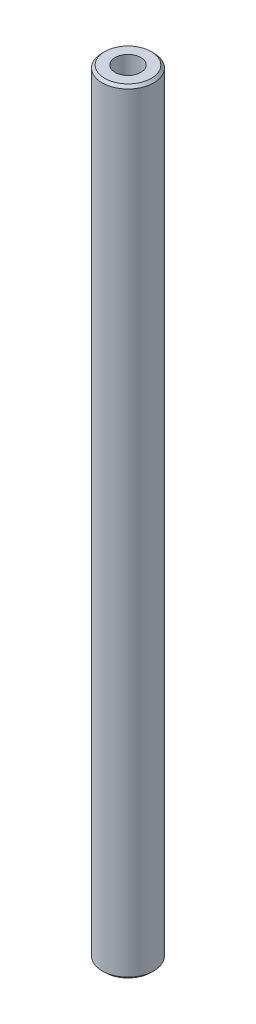
from build123d import *

# Parameters (mm, degrees)
ESQUISSE1_R      = 5
EXTRUSION1_DEPTH = 150
CHANFREIN1_SIZE  = 0.5
ESQUISSE2_R      = 2.5
EXTRUSION2_DEPTH = 15
ESQUISSE3_R      = 2.5
EXTRUSION3_DEPTH = 15


with BuildPart() as part:
    # Esquisse1 → Extrusion1 (new body)
    with BuildSketch(Plane(origin=(0, 0, 0), x_dir=(1, 0, 0), z_dir=(0, 1, 0))):
        Circle(ESQUISSE1_R)
    extrude(amount=EXTRUSION1_DEPTH)

    # Chanfrein1
    chanfrein1_edges = [part.edges().sort_by_distance(p)[0] for p in [
        (-5, 0, 0),
        (-5, 150, 0),
    ]]
    chamfer(chanfrein1_edges, length=CHANFREIN1_SIZE)

    # Esquisse2 → Extrusion2 (cut)
    with BuildSketch(Plane.XZ):
        Circle(ESQUISSE2_R)
    extrude(amount=-EXTRUSION2_DEPTH, mode=Mode.SUBTRACT)

    # Esquisse3 → Extrusion3 (cut)
    with BuildSketch(Plane(origin=(0, 150, 0), x_dir=(1, 0, 0), z_dir=(0, 1, 0))):
        Circle(ESQUISSE3_R)
    extrude(amount=-EXTRUSION3_DEPTH, mode=Mode.SUBTRACT)


solid = part.part
